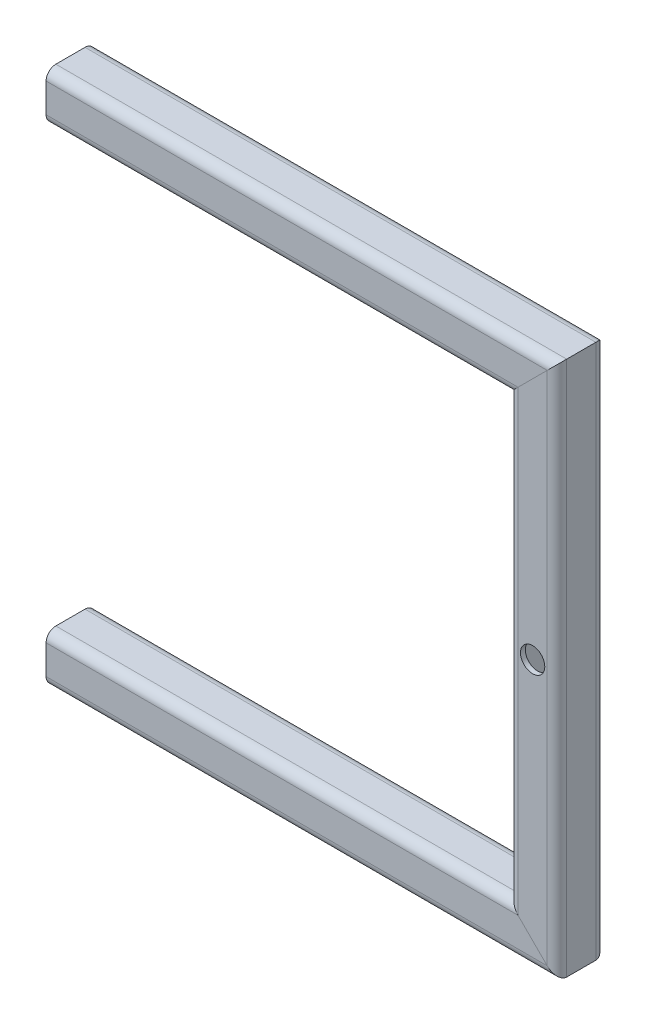
from build123d import *

# Parameters (mm, degrees)
SQUARE_TUBE_20_X_20_X_2_1_DEPTH   = 215.142135624
SQUARE_TUBE_20_X_20_X_2_1_2_DEPTH = 230.284271247
SQUARE_TUBE_20_X_20_X_2_1_3_DEPTH = 215.142135624
SKETCH12_R                        = 5
CUT_EXTRUDE1_DEPTH                = 298.153159162
CUT_EXTRUDE1_DEPTH_BACK           = 298.153159162


with BuildPart() as part:
    # Sketch11 → Square tube 20 X 20 X 2(1) (new body)
    with BuildSketch(Plane.YZ):
        with BuildLine():
            Line((-6, -10), (6, -10))
            ThreePointArc((6, -10), (8.828427125, -8.828427125), (10, -6))
            Line((10, -6), (10, 6))
            ThreePointArc((10, 6), (8.828427125, 8.828427125), (6, 10))
            Line((6, 10), (-6, 10))
            ThreePointArc((-6, 10), (-8.828427125, 8.828427125), (-10, 6))
            Line((-10, 6), (-10, -6))
            ThreePointArc((-10, -6), (-8.828427125, -8.828427125), (-6, -10))
        make_face()
        with BuildLine():
            Line((-6, -8), (6, -8))
            ThreePointArc((6, -8), (7.414213562, -7.414213562), (8, -6))
            Line((8, -6), (8, 6))
            ThreePointArc((8, 6), (7.414213562, 7.414213562), (6, 8))
            Line((6, 8), (-6, 8))
            ThreePointArc((-6, 8), (-7.414213562, 7.414213562), (-8, 6))
            Line((-8, 6), (-8, -6))
            ThreePointArc((-8, -6), (-7.414213562, -7.414213562), (-6, -8))
        make_face(mode=Mode.SUBTRACT)
    extrude(amount=SQUARE_TUBE_20_X_20_X_2_1_DEPTH)

    # Square tube 20 X 20 X 2(1) mitre 1
    split(bisect_by=Plane(origin=(200, 0, 0), x_dir=(0.707106781, -0.707106781, 0), z_dir=(-0.707106781, -0.707106781, 0)), keep=Keep.TOP)


with BuildPart() as body_2:
    # Sketch11 on segment 2 (carried to segment 2) → Square tube 20 X 20 X 2_1 2 (new body)
    with BuildSketch(Plane(origin=(200, -15.142135624, 0), x_dir=(-1, 0, 0), z_dir=(0, 1, 0))):
        with BuildLine():
            Line((-6, -10), (6, -10))
            ThreePointArc((6, -10), (8.828427125, -8.828427125), (10, -6))
            Line((10, -6), (10, 6))
            ThreePointArc((10, 6), (8.828427125, 8.828427125), (6, 10))
            Line((6, 10), (-6, 10))
            ThreePointArc((-6, 10), (-8.828427125, 8.828427125), (-10, 6))
            Line((-10, 6), (-10, -6))
            ThreePointArc((-10, -6), (-8.828427125, -8.828427125), (-6, -10))
        make_face()
        with BuildLine():
            Line((-6, -8), (6, -8))
            ThreePointArc((6, -8), (7.414213562, -7.414213562), (8, -6))
            Line((8, -6), (8, 6))
            ThreePointArc((8, 6), (7.414213562, 7.414213562), (6, 8))
            Line((6, 8), (-6, 8))
            ThreePointArc((-6, 8), (-7.414213562, 7.414213562), (-8, 6))
            Line((-8, 6), (-8, -6))
            ThreePointArc((-8, -6), (-7.414213562, -7.414213562), (-6, -8))
        make_face(mode=Mode.SUBTRACT)
    extrude(amount=SQUARE_TUBE_20_X_20_X_2_1_2_DEPTH)

    # Square tube 20 X 20 X 2_1 2 mitre 1
    split(bisect_by=Plane(origin=(200, 0, 0), x_dir=(-0.707106781, 0.707106781, 0), z_dir=(0.707106781, 0.707106781, 0)), keep=Keep.TOP)

    # Square tube 20 X 20 X 2_1 2 mitre 2
    split(bisect_by=Plane(origin=(200, 200, 0), x_dir=(0.707106781, 0.707106781, 0), z_dir=(0.707106781, -0.707106781, 0)), keep=Keep.TOP)

    # Sketch12 → Cut-Extrude1 (cut, two sides)
    with BuildSketch(Plane.XY) as cut_extrude1_sk:
        with Locations((200, 100)):
            Circle(SKETCH12_R)
    extrude(amount=CUT_EXTRUDE1_DEPTH, mode=Mode.SUBTRACT)
    extrude(cut_extrude1_sk.sketch, amount=-CUT_EXTRUDE1_DEPTH_BACK, mode=Mode.SUBTRACT)


with BuildPart() as body_3:
    # Sketch11 on segment 3 (carried to segment 3) → Square tube 20 X 20 X 2_1 3 (new body)
    with BuildSketch(Plane(origin=(215.142135624, 200, 0), x_dir=(0, -1, 0), z_dir=(-1, 0, 0))):
        with BuildLine():
            Line((-6, -10), (6, -10))
            ThreePointArc((6, -10), (8.828427125, -8.828427125), (10, -6))
            Line((10, -6), (10, 6))
            ThreePointArc((10, 6), (8.828427125, 8.828427125), (6, 10))
            Line((6, 10), (-6, 10))
            ThreePointArc((-6, 10), (-8.828427125, 8.828427125), (-10, 6))
            Line((-10, 6), (-10, -6))
            ThreePointArc((-10, -6), (-8.828427125, -8.828427125), (-6, -10))
        make_face()
        with BuildLine():
            Line((-6, -8), (6, -8))
            ThreePointArc((6, -8), (7.414213562, -7.414213562), (8, -6))
            Line((8, -6), (8, 6))
            ThreePointArc((8, 6), (7.414213562, 7.414213562), (6, 8))
            Line((6, 8), (-6, 8))
            ThreePointArc((-6, 8), (-7.414213562, 7.414213562), (-8, 6))
            Line((-8, 6), (-8, -6))
            ThreePointArc((-8, -6), (-7.414213562, -7.414213562), (-6, -8))
        make_face(mode=Mode.SUBTRACT)
    extrude(amount=SQUARE_TUBE_20_X_20_X_2_1_3_DEPTH)

    # Square tube 20 X 20 X 2_1 3 mitre 1
    split(bisect_by=Plane(origin=(200, 200, 0), x_dir=(-0.707106781, -0.707106781, 0), z_dir=(-0.707106781, 0.707106781, 0)), keep=Keep.TOP)


solid = Compound([part.part, body_2.part, body_3.part])
